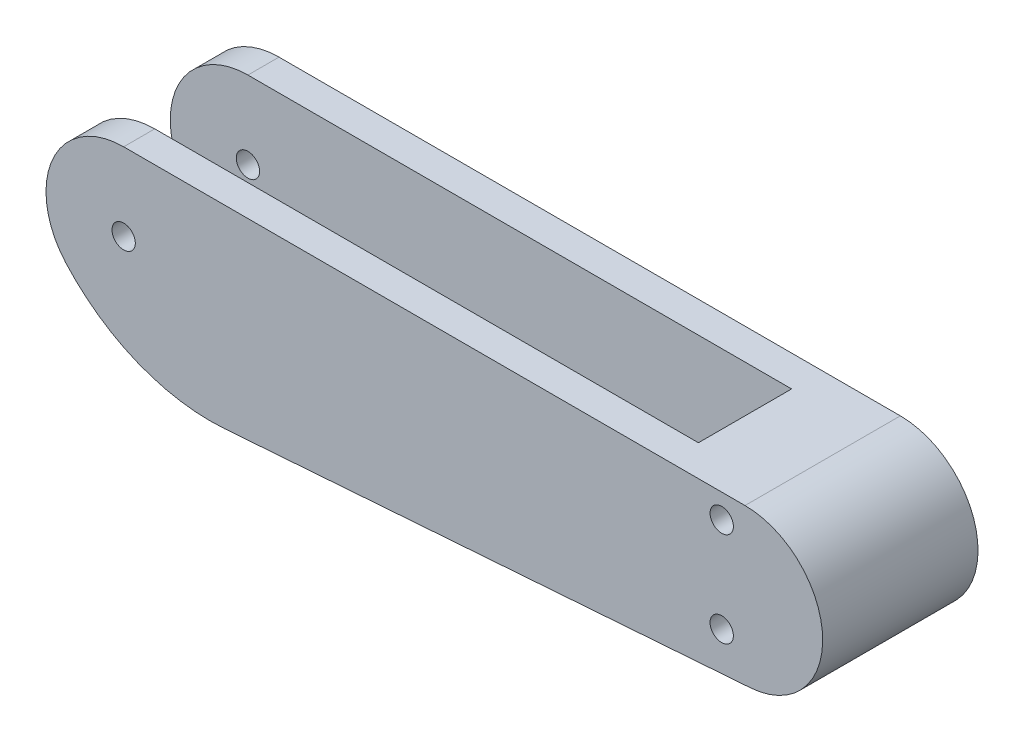
from build123d import *

# Parameters (mm, degrees)
SKETCH1_R               = 1.5
BOSS_EXTRUDE1_DEPTH     = 10
SKETCH2_W               = 140
SKETCH2_H               = 12
CUT_EXTRUDE1_DEPTH      = 11
CUT_EXTRUDE1_DEPTH_BACK = 16


with BuildPart() as part:
    # Sketch1 → Boss-Extrude1 (new body, symmetric)
    with BuildSketch(Plane.XY):
        with BuildLine():
            Line((43.628033294, 10), (0, 10))
            ThreePointArc((0, 10), (-9.128709292, 4.082482905), (-7.453559925, -6.666666667))
            ThreePointArc((-7.453559925, -6.666666667), (1.814979124, -13.179517203), (13.006384648, -14.933222025))
            Line((13.006384648, -14.933222025), (80.730417904, -9.97328881))
            ThreePointArc((80.730417904, -9.97328881), (89.993319971, 0.365453076), (80, 10))
            Line((80, 10), (43.628033294, 10))
        make_face()
        with Locations((77, -5.283013816)):
            Circle(SKETCH1_R, mode=Mode.SUBTRACT)
        with Locations((77, 6.904943152)):
            Circle(SKETCH1_R, mode=Mode.SUBTRACT)
        Circle(SKETCH1_R, mode=Mode.SUBTRACT)
    extrude(amount=BOSS_EXTRUDE1_DEPTH, both=True)

    # Sketch2 → Cut-Extrude1 (cut, two sides)
    with BuildSketch(Plane(origin=(0, 0, 0), x_dir=(1, 0, 0), z_dir=(0, 1, 0))) as cut_extrude1_sk:
        Rectangle(SKETCH2_W, SKETCH2_H)
    extrude(amount=CUT_EXTRUDE1_DEPTH, mode=Mode.SUBTRACT)
    extrude(cut_extrude1_sk.sketch, amount=-CUT_EXTRUDE1_DEPTH_BACK, mode=Mode.SUBTRACT)


solid = part.part
